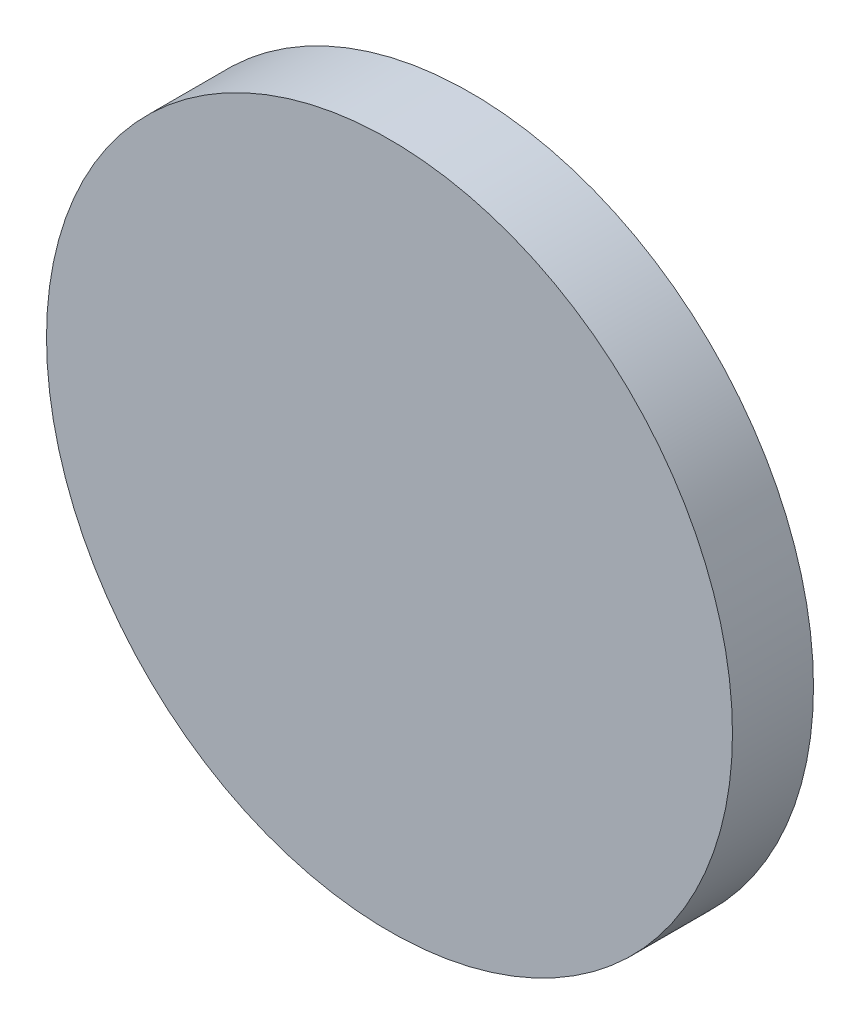
from build123d import *

# Parameters (mm, degrees)
SKETCH_1_R      = 12.7
EXTRUDE_1_DEPTH = 3


with BuildPart() as part:
    # 草图1 → 凸台-拉伸1 (new body)
    with BuildSketch(Plane.XY):
        Circle(SKETCH_1_R)
    extrude(amount=EXTRUDE_1_DEPTH)


solid = part.part
